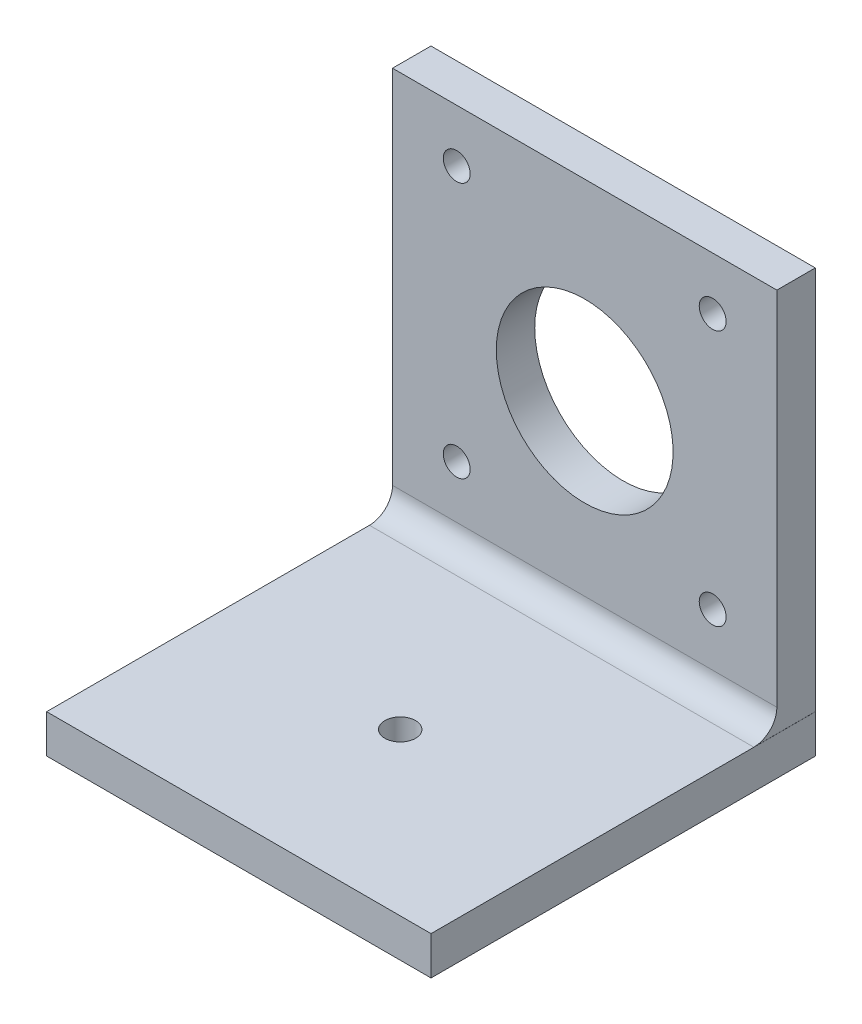
from build123d import *

# Parameters (mm, degrees)
ESBO_O1_W                  = 50
ESBO_O1_H                  = 50
RESSALTO_EXTRUS_O1_DEPTH   = 5
ESBO_O2_R                  = 11.5
CORTE_EXTRUS_O1_DEPTH      = 8
CORTE_EXTRUS_O1_DEPTH_BACK = 14
ESBO_O3_W                  = 50.011024838
ESBO_O3_H                  = 5
RESSALTO_EXTRUS_O2_DEPTH   = 50
FILETE1_R                  = 3
ESBO_O4_R                  = 1.75
CORTE_EXTRUS_O2_DEPTH      = 11
ESBO_O5_R                  = 2
CORTE_EXTRUS_O4_DEPTH      = 14


with BuildPart() as part:
    # Esboço1 → Ressalto-extrusão1 (new body)
    with BuildSketch(Plane.XY):
        with Locations((25, 25)):
            Rectangle(ESBO_O1_W, ESBO_O1_H)
    extrude(amount=RESSALTO_EXTRUS_O1_DEPTH)

    # Esboço2 → Corte-extrusão1 (cut, two sides)
    with BuildSketch(Plane.XY) as corte_extrus_o1_sk:
        with Locations((25, 25)):
            Circle(ESBO_O2_R)
    extrude(amount=CORTE_EXTRUS_O1_DEPTH, mode=Mode.SUBTRACT)
    extrude(corte_extrus_o1_sk.sketch, amount=-CORTE_EXTRUS_O1_DEPTH_BACK, mode=Mode.SUBTRACT)

    # Esboço3 → Ressalto-extrusão2 (add)
    with BuildSketch(Plane.XY):
        with Locations((25.005512419, -2.5)):
            Rectangle(ESBO_O3_W, ESBO_O3_H)
    extrude(amount=RESSALTO_EXTRUS_O2_DEPTH)

    # Filete1
    filete1_edges = [part.edges().sort_by_distance(p)[0] for p in [
        (25, 0, 5),
    ]]
    fillet(filete1_edges, radius=FILETE1_R)

    # Esboço4 → Corte-extrusão2 (cut)
    with BuildSketch(Plane.XY):
        with Locations((8.35, 43.15)):
            Circle(ESBO_O4_R)
        with Locations((41.65, 43.15)):
            Circle(ESBO_O4_R)
        with Locations((41.65, 9.85)):
            Circle(ESBO_O4_R)
        with Locations((8.35, 9.85)):
            Circle(ESBO_O4_R)
    extrude(amount=CORTE_EXTRUS_O2_DEPTH, mode=Mode.SUBTRACT)

    # Esboço5 → Corte-extrusão4 (cut)
    with BuildSketch(Plane(origin=(0, 0, 0), x_dir=(1, 0, 0), z_dir=(0, 1, 0))):
        with Locations((25.002756209, -29)):
            Circle(ESBO_O5_R)
    extrude(amount=-CORTE_EXTRUS_O4_DEPTH, mode=Mode.SUBTRACT)


solid = part.part
